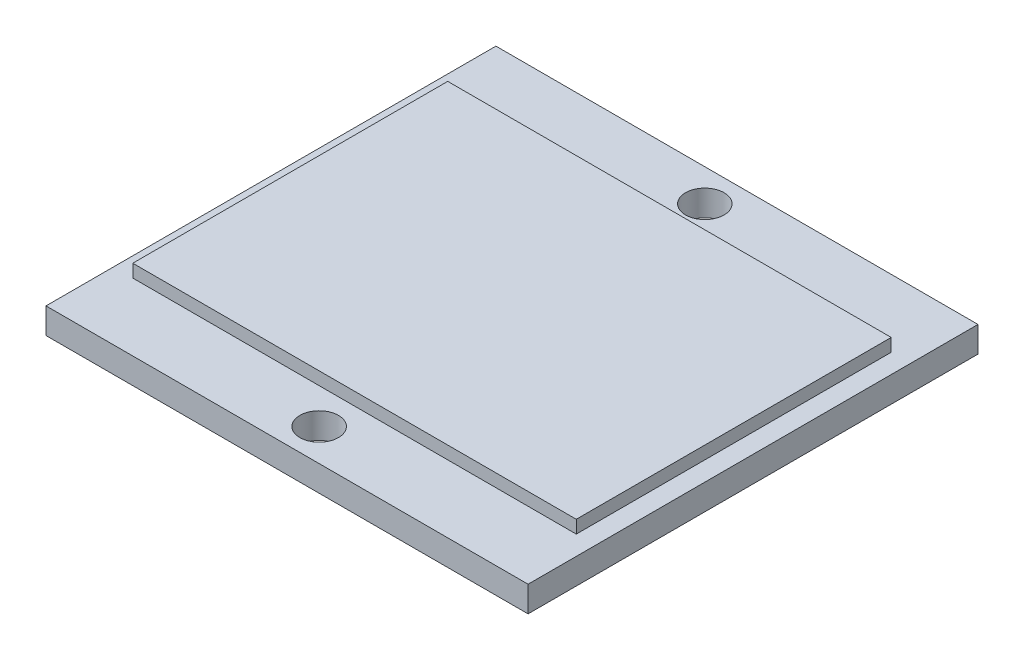
from build123d import *

# Parameters (mm, degrees)
SKETCH1_W           = 75
SKETCH1_H           = 70
BOSS_EXTRUDE1_DEPTH = 4
SKETCH2_W           = 69
SKETCH2_H           = 49
BOSS_EXTRUDE2_DEPTH = 2
SKETCH3_R           = 3
CUT_EXTRUDE1_DEPTH  = 4


with BuildPart() as part:
    # Sketch1 → Boss-Extrude1 (new body)
    with BuildSketch(Plane(origin=(0, 0, 0), x_dir=(1, 0, 0), z_dir=(0, 1, 0))):
        with Locations((12.572182046, -15.652440212)):
            Rectangle(SKETCH1_W, SKETCH1_H)
    extrude(amount=BOSS_EXTRUDE1_DEPTH)

    # Sketch2 → Boss-Extrude2 (add)
    with BuildSketch(Plane(origin=(0, 4, 0), x_dir=(1, 0, 0), z_dir=(0, 1, 0))):
        with Locations((12.572182046, -15.652440212)):
            Rectangle(SKETCH2_W, SKETCH2_H)
    extrude(amount=BOSS_EXTRUDE2_DEPTH)

    # Sketch3 → Cut-Extrude1 (cut)
    with BuildSketch(Plane(origin=(0, 4, 0), x_dir=(1, 0, 0), z_dir=(0, 1, 0))):
        with Locations((12.572182046, 14.347559788)):
            Circle(SKETCH3_R)
        with Locations((12.572182046, -45.652440212)):
            Circle(SKETCH3_R)
    extrude(amount=-CUT_EXTRUDE1_DEPTH, mode=Mode.SUBTRACT)


solid = part.part
